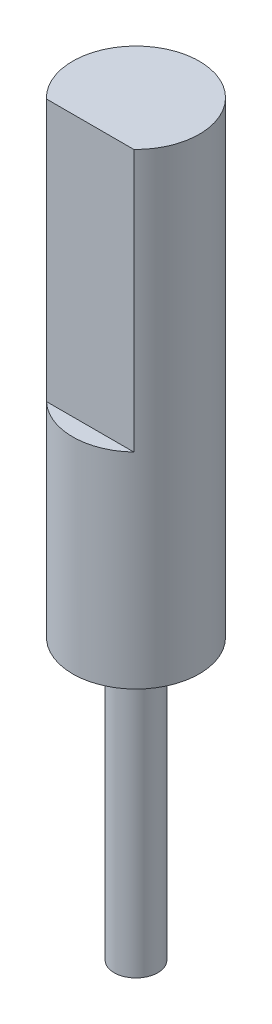
from build123d import *

# Parameters (mm, degrees)
CROQUIS1_R              = 1.45
SALIENTE_EXTRUIR1_DEPTH = 10.7
CORTAR_EXTRUIR1_DEPTH   = 6
CROQUIS3_R              = 0.5
SALIENTE_EXTRUIR2_DEPTH = 6.4


with BuildPart() as part:
    # Croquis1 → Saliente-Extruir1 (new body)
    with BuildSketch(Plane(origin=(0, 0, 0), x_dir=(1, 0, 0), z_dir=(0, 1, 0))):
        Circle(CROQUIS1_R)
    extrude(amount=SALIENTE_EXTRUIR1_DEPTH)

    # Croquis2 → Cortar-Extruir1 (cut)
    with BuildSketch(Plane(origin=(0, 10.7, 0), x_dir=(1, 0, 0), z_dir=(0, 1, 0))):
        with BuildLine():
            Line((-1, -1.05), (1, -1.05))
            ThreePointArc((1, -1.05), (0, -1.45), (-1, -1.05))
        make_face()
    extrude(amount=-CORTAR_EXTRUIR1_DEPTH, mode=Mode.SUBTRACT)

    # Croquis3 → Saliente-Extruir2 (add)
    with BuildSketch(Plane.XZ):
        Circle(CROQUIS3_R)
    extrude(amount=SALIENTE_EXTRUIR2_DEPTH)


solid = part.part
